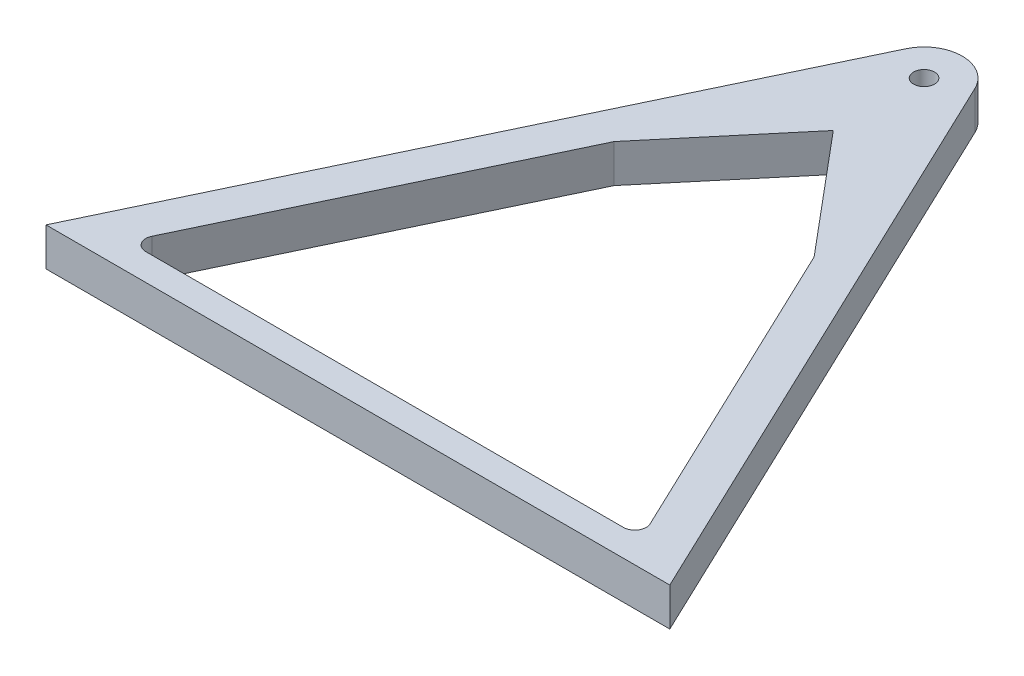
from build123d import *

# Parameters (mm, degrees)
BOSS_EXTRUDE1_DEPTH = 10
FILLET1_R           = 10
FILLET2_R           = 3
SKETCH5_R           = 10
BOSS_EXTRUDE2_DEPTH = 10
SKETCH4_R           = 2.75
CUT_EXTRUDE1_DEPTH  = 10
BOSS_EXTRUDE3_DEPTH = 10


with BuildPart() as part:
    # Sketch1 → Boss-Extrude1 (new body)
    with BuildSketch(Plane(origin=(0, 0, 0), x_dir=(1, 0, 0), z_dir=(0, 1, 0))):
        Polygon((-81.738081939, 0), (0, 171.628518507), (81.738081939, 0), align=None)
        Polygon((0, 148.371481493), (-67.328168061, 7), (67.328168061, 7), align=None, mode=Mode.SUBTRACT)
    extrude(amount=BOSS_EXTRUDE1_DEPTH)

    # Fillet1
    fillet1_edges = [part.edges().sort_by_distance(p)[0] for p in [
        (0, 5, -171.628518507),
    ]]
    fillet(fillet1_edges, radius=FILLET1_R)

    # Fillet2
    fillet2_edges = [part.edges().sort_by_distance(p)[0] for p in [
        (0, 5, -148.371481493),
        (-67.328168061, 5, -7),
        (67.328168061, 5, -7),
    ]]
    fillet(fillet2_edges, radius=FILLET2_R)

    # Sketch5 → Boss-Extrude2 (add, through all)
    with BuildSketch(Plane(origin=(0, 10, 0), x_dir=(1, 0, 0), z_dir=(0, 1, 0))):
        with Locations((0, 148.371481493)):
            Circle(SKETCH5_R)
    extrude(amount=-BOSS_EXTRUDE2_DEPTH)

    # Sketch4 → Cut-Extrude1 (cut)
    with BuildSketch(Plane(origin=(0, 10, 0), x_dir=(1, 0, 0), z_dir=(0, 1, 0))):
        with Locations((0, 148.371481493)):
            Circle(SKETCH4_R)
    extrude(amount=-CUT_EXTRUDE1_DEPTH, mode=Mode.SUBTRACT)

    # Sketch6 → Boss-Extrude3 (add, through all)
    with BuildSketch(Plane(origin=(0, 10, 0), x_dir=(1, 0, 0), z_dir=(0, 1, 0))):
        with BuildLine():
            Line((-26.19375, 93.371481493), (0, 124.587977159))
            Line((0, 124.587977159), (26.19375, 93.371481493))
            Line((26.19375, 93.371481493), (4.299773868, 139.34308492))
            ThreePointArc((4.299773868, 139.34308492), (0, 138.371481493), (-4.299773868, 139.34308492))
            Line((-4.299773868, 139.34308492), (-26.19375, 93.371481493))
        make_face()
    extrude(amount=-BOSS_EXTRUDE3_DEPTH)


solid = part.part
